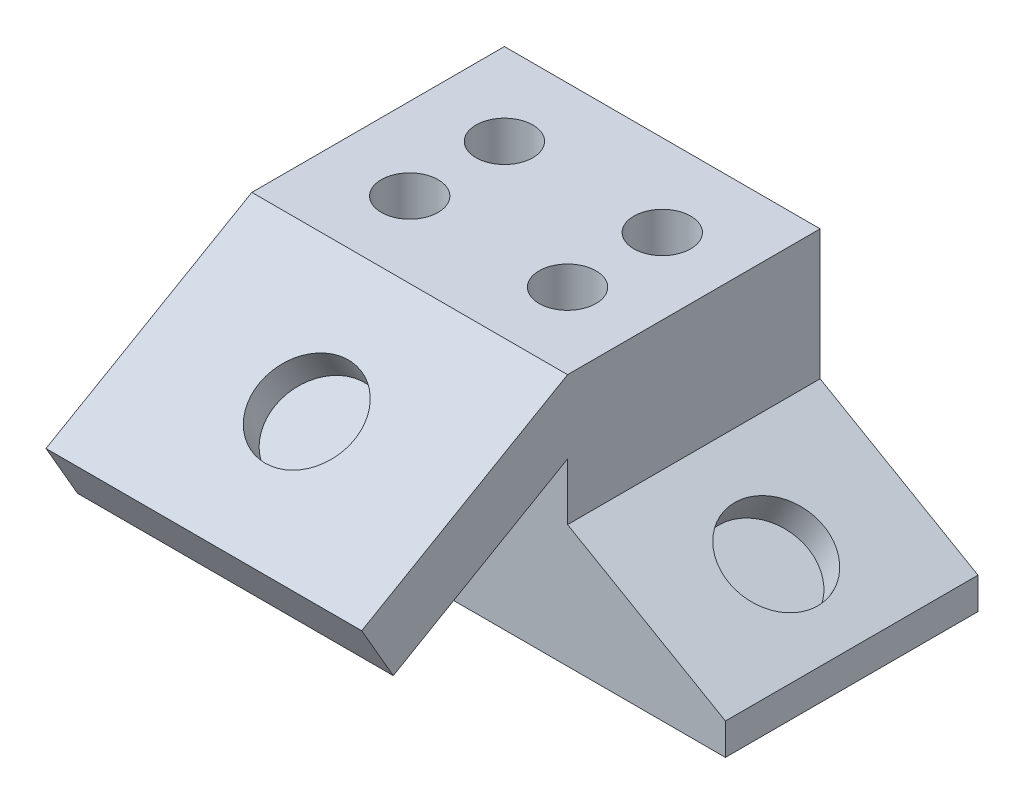
from build123d import *

# Parameters (mm, degrees)
SKETCH1_W           = 63.5
SKETCH1_H           = 50.8
BOSS_EXTRUDE1_DEPTH = 50.8
BOSS_EXTRUDE2_DEPTH = 50.8
SKETCH3_R           = 9.652
CUT_EXTRUDE2_DEPTH  = 6.35
BOSS_EXTRUDE3_DEPTH = 63.5
SKETCH6_R           = 9.652
CUT_EXTRUDE4_DEPTH  = 6.35
SKETCH7_R           = 5.715
CUT_EXTRUDE6_DEPTH  = 12.7


with BuildPart() as part:
    # Sketch1 → Boss-Extrude1 (new body)
    with BuildSketch(Plane(origin=(0, 0, 0), x_dir=(1, 0, 0), z_dir=(0, 1, 0))):
        Rectangle(SKETCH1_W, SKETCH1_H)
    extrude(amount=BOSS_EXTRUDE1_DEPTH)

    # Sketch2 → Boss-Extrude2 (add)
    with BuildSketch(Plane.XY.offset(25.4)):
        Polygon((63.5, 6.35), (31.75, 24.680871047), (31.75, 0), (63.5, 0), align=None)
    extrude(amount=-BOSS_EXTRUDE2_DEPTH)

    # Sketch3 → Cut-Extrude2 (cut)
    with BuildSketch(Plane(origin=(18.624630657, 32.25880657, 0), x_dir=(0.866025404, -0.5, 0), z_dir=(0.5, 0.866025404, 0))):
        with Locations((34.289443039, 0)):
            Circle(SKETCH3_R)
    extrude(amount=-CUT_EXTRUDE2_DEPTH, mode=Mode.SUBTRACT)

    # Sketch5 → Boss-Extrude3 (add, through all)
    with BuildSketch(Plane(origin=(31.75, 0, 0), x_dir=(0, 0, -1), z_dir=(1, 0, 0))):
        Polygon((-25.4, 50.8), (-66.802, 26.896544155), (-60.452, 15.898021527), (-25.4, 36.135303163), align=None)
    extrude(amount=-BOSS_EXTRUDE3_DEPTH)

    # Sketch6 → Cut-Extrude4 (cut)
    with BuildSketch(Plane(origin=(0, 49.098522628, 28.347045256), x_dir=(1, 0, 0), z_dir=(0, 0.866025404, 0.5))):
        with Locations((0, -20.500501101)):
            Circle(SKETCH6_R)
    extrude(amount=-CUT_EXTRUDE4_DEPTH, mode=Mode.SUBTRACT)

    # Sketch7 → Cut-Extrude6 (cut)
    with BuildSketch(Plane(origin=(0, 50.8, 0), x_dir=(1, 0, 0), z_dir=(0, 1, 0))):
        with Locations((-15.24, -10.16)):
            Circle(SKETCH7_R)
        with Locations((-15.24, 8.89)):
            Circle(SKETCH7_R)
        with Locations((16.51, -10.16)):
            Circle(SKETCH7_R)
        with Locations((16.51, 8.89)):
            Circle(SKETCH7_R)
    extrude(amount=-CUT_EXTRUDE6_DEPTH, mode=Mode.SUBTRACT)


solid = part.part
